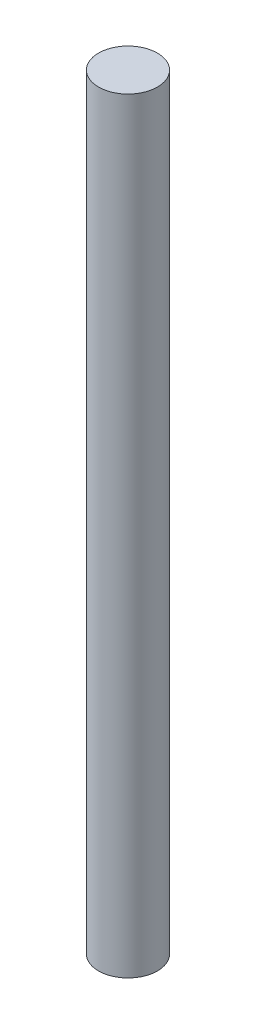
from build123d import *

# Parameters (mm, degrees)
SKETCH1_R           = 152.4
BOSS_EXTRUDE1_DEPTH = 3962.4


with BuildPart() as part:
    # Sketch1 → Boss-Extrude1 (new body)
    with BuildSketch(Plane(origin=(0, 0, 0), x_dir=(1, 0, 0), z_dir=(0, 1, 0))):
        Circle(SKETCH1_R)
    extrude(amount=BOSS_EXTRUDE1_DEPTH)


solid = part.part
